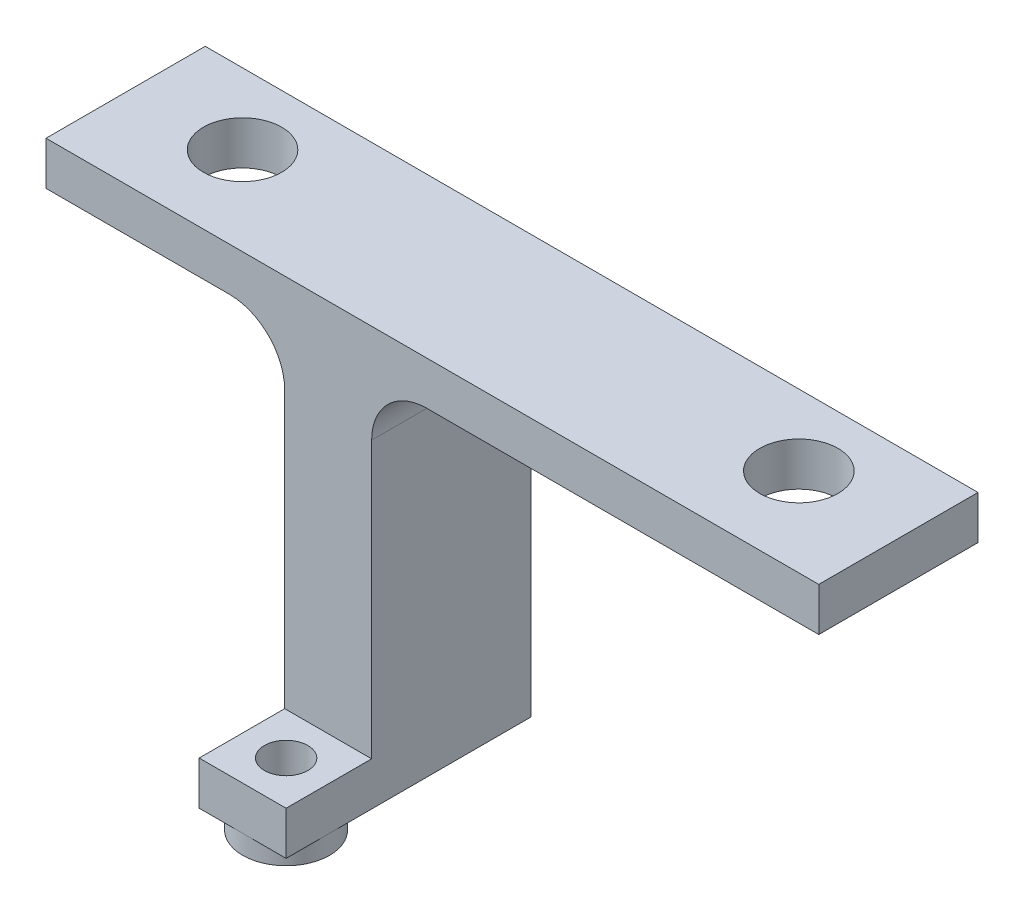
from build123d import *

# Parameters (mm, degrees)
SKETCH1_W           = 44.45
SKETCH1_H           = 10.16
SKETCH1_R           = 2.25
BOSS_EXTRUDE1_DEPTH = 2.5
SKETCH3_W           = 5
SKETCH3_H           = 10.16
BOSS_EXTRUDE2_DEPTH = 19.05
SKETCH5_W           = 5
SKETCH5_H           = 15.08
SKETCH5_R           = 1.25
BOSS_EXTRUDE3_DEPTH = 2.5
SKETCH6_R           = 2.5
SKETCH6_R_2         = 1.25
BOSS_EXTRUDE4_DEPTH = 1.1
FILLET1_R           = 3.175
CUT_EXTRUDE1_DEPTH  = 1


with BuildPart() as part:
    # Sketch1 → Boss-Extrude1 (new body)
    with BuildSketch(Plane(origin=(0, 0, 0), x_dir=(1, 0, 0), z_dir=(0, 1, 0))):
        Rectangle(SKETCH1_W, SKETCH1_H)
        with Locations((-16, 0)):
            Circle(SKETCH1_R, mode=Mode.SUBTRACT)
        with Locations((16, 0)):
            Circle(SKETCH1_R, mode=Mode.SUBTRACT)
    extrude(amount=BOSS_EXTRUDE1_DEPTH)

    # Sketch3 → Boss-Extrude2 (add)
    with BuildSketch(Plane(origin=(0, 0, 0), x_dir=(-1, 0, 0), z_dir=(0, -1, 0))):
        with Locations((5.9944, 0)):
            Rectangle(SKETCH3_W, SKETCH3_H)
    extrude(amount=BOSS_EXTRUDE2_DEPTH)

    # Sketch5 → Boss-Extrude3 (add)
    with BuildSketch(Plane.XZ.offset(19.05)):
        with Locations((-5.9944, 2.46)):
            Rectangle(SKETCH5_W, SKETCH5_H)
        with Locations((-5.9944, 7.5)):
            Circle(SKETCH5_R, mode=Mode.SUBTRACT)
    extrude(amount=BOSS_EXTRUDE3_DEPTH)

    # Sketch6 → Boss-Extrude4 (add)
    with BuildSketch(Plane.XZ.offset(21.55)):
        with Locations((-5.9944, 7.5)):
            Circle(SKETCH6_R)
        with Locations((-5.9944, 7.5)):
            Circle(SKETCH6_R_2, mode=Mode.SUBTRACT)
    extrude(amount=BOSS_EXTRUDE4_DEPTH)

    # Fillet1
    fillet1_edges = [part.edges().sort_by_distance(p)[0] for p in [
        (-3.4944, 0, 0),
        (-8.4944, 0, 0),
    ]]
    fillet(fillet1_edges, radius=FILLET1_R)

    # Sketch7 → Cut-Extrude1 (cut)
    with BuildSketch(Plane(origin=(0, 0, -5.08), x_dir=(-1, 0, 0), z_dir=(0, 0, -1))):
        with BuildLine():
            Line((-22.225, 0), (0.3194, 0))
            ThreePointArc((0.3194, 0), (2.56446403, -0.92993597), (3.4944, -3.175))
            Line((3.4944, -3.175), (3.4944, -21.55))
            Line((3.4944, -21.55), (8.4944, -21.55))
            Line((8.4944, -21.55), (8.4944, -3.175))
            ThreePointArc((8.4944, -3.175), (9.42433597, -0.92993597), (11.6694, 0))
            Line((11.6694, 0), (22.225, 0))
            Line((22.225, 0), (22.225, 2.5))
            Line((22.225, 2.5), (-22.225, 2.5))
            Line((-22.225, 2.5), (-22.225, 0))
        make_face()
    extrude(amount=-CUT_EXTRUDE1_DEPTH, mode=Mode.SUBTRACT)


solid = part.part
